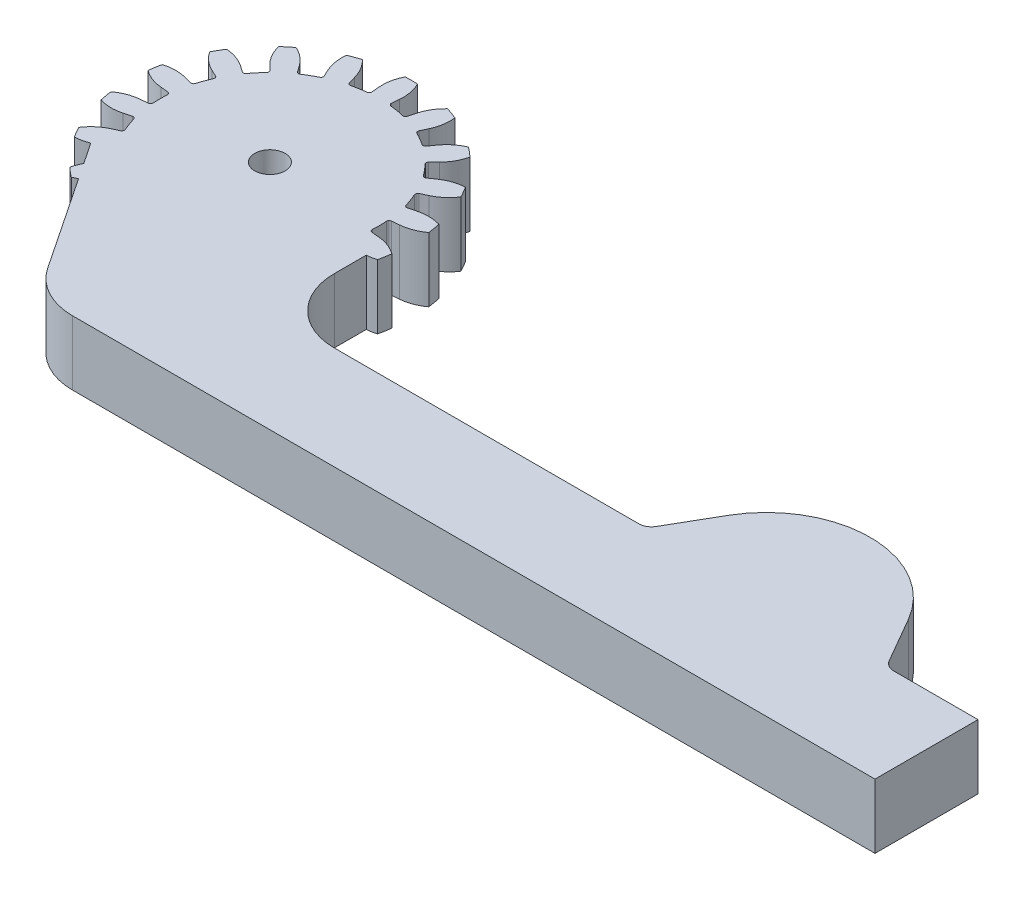
from build123d import *

# Parameters (mm, degrees)
BOSS_EXTRUDE1_DEPTH = 6.35
CIRPATTERN1_COUNT   = 18
BOSS_EXTRUDE3_START = -6.35
BOSS_EXTRUDE3_DEPTH = 6.35
SKETCH4_R           = 1.500000048
CUT_EXTRUDE1_DEPTH  = 6.35


with BuildPart() as part:
    # Sketch1 → Boss-Extrude1 (new body)
    with BuildSketch(Plane(origin=(0, 0, 0), x_dir=(1, 0, 0), z_dir=(0, 1, 0))):
        with BuildLine():
            Line((0, 0), (-1.880045408, 10.66226734))
            ThreePointArc((-1.880045408, 10.66226734), (-1.536116928, 10.717222604), (-1.190598755, 10.761086849))
            ThreePointArc((-1.190598755, 10.761086849), (-1.022096794, 10.852519273), (-0.965497238, 11.035683923))
            Line((-0.965497238, 11.035683923), (-1.029695335, 11.769471531))
            ThreePointArc((-1.029695335, 11.769471531), (-0.972041848, 12.892396814), (-0.609362841, 13.956703655))
            ThreePointArc((-0.609362841, 13.956703655), (0, 13.97), (0.609362841, 13.956703655))
            ThreePointArc((0.609362841, 13.956703655), (0.972041848, 12.892396814), (1.029695335, 11.769471531))
            Line((1.029695335, 11.769471531), (0.965497238, 11.035683923))
            ThreePointArc((0.965497238, 11.035683923), (1.022096794, 10.852519273), (1.190598755, 10.761086849))
            ThreePointArc((1.190598755, 10.761086849), (1.536116928, 10.717222604), (1.880045408, 10.66226734))
            Line((1.880045408, 10.66226734), (0, 0))
        make_face()
    boss_extrude1 = extrude(amount=BOSS_EXTRUDE1_DEPTH)

    # CirPattern1: Boss-Extrude1 ×18 about axis
    cirpattern1_axis = Axis((0, 0, 0), (0, 1, 0))
    for i in range(1, CIRPATTERN1_COUNT):
        add(boss_extrude1.rotate(cirpattern1_axis, i * 360 / CIRPATTERN1_COUNT))

    # Sketch2 → Boss-Extrude3 (add)
    with BuildSketch(Plane(origin=(0, 6.35, 0), x_dir=(1, 0, 0), z_dir=(0, 1, 0)).offset(BOSS_EXTRUDE3_START)):
        with BuildLine():
            Line((49.084416739, -12.7), (19.05, -12.7))
            ThreePointArc((19.05, -12.7), (14.559871939, -10.840128061), (12.7, -6.35))
            Line((12.7, -6.35), (12.7, -3.175))
            Line((12.7, -3.175), (0, 0))
            Line((0, 0), (-10.559788625, -7.055555556))
            Line((-10.559788625, -7.055555556), (-1.88567654, -20.037777778))
            ThreePointArc((-1.88567654, -20.037777778), (0.400799065, -22.110173608), (3.394217772, -22.86))
            Line((3.394217772, -22.86), (82.55, -22.86))
            Line((82.55, -22.86), (82.55, -12.7))
            Line((82.55, -12.7), (74.249409051, -12.7))
            ThreePointArc((74.249409051, -12.7), (73.614409051, -12.529852263), (73.149556788, -12.065))
            Line((73.149556788, -12.065), (70.553858881, -7.569119343))
            ThreePointArc((70.553858881, -7.569119343), (61.666912895, -2.438238686), (52.77996691, -7.569119343))
            Line((52.77996691, -7.569119343), (50.184269002, -12.065))
            ThreePointArc((50.184269002, -12.065), (49.719416739, -12.529852263), (49.084416739, -12.7))
        make_face()
    extrude(amount=BOSS_EXTRUDE3_DEPTH)

    # Sketch4 → Cut-Extrude1 (cut)
    with BuildSketch(Plane(origin=(0, 6.35, 0), x_dir=(1, 0, 0), z_dir=(0, 1, 0))):
        Circle(SKETCH4_R)
    extrude(amount=-CUT_EXTRUDE1_DEPTH, mode=Mode.SUBTRACT)


solid = part.part
